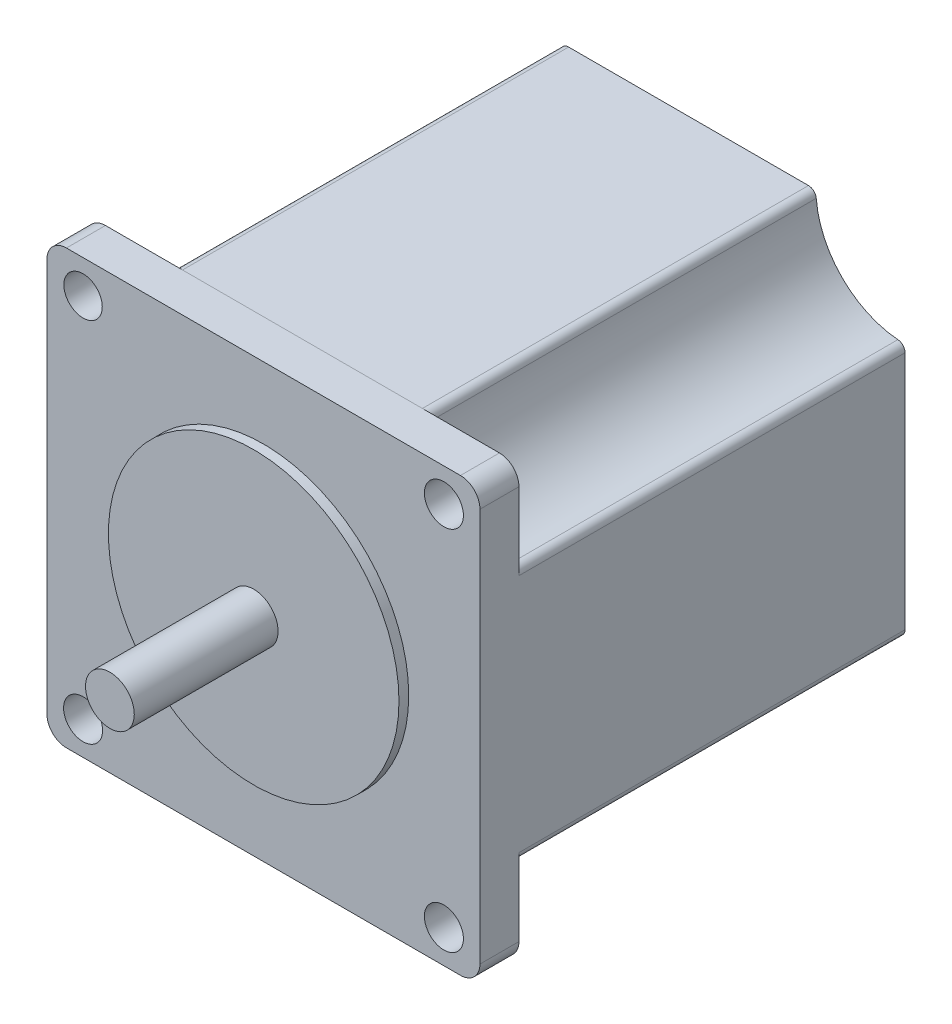
from build123d import *

# Parameters (mm, degrees)
BOSS_EXTRUDE1_DEPTH = 5.08
SKETCH2_R           = 2.5
SKETCH2_R_2         = 2.54
CUT_EXTRUDE1_DEPTH  = 12.7
SKETCH3_R           = 3.175
BOSS_EXTRUDE2_DEPTH = 20
BOSS_EXTRUDE3_DEPTH = 50.292
SKETCH7_R           = 5.08
CUT_EXTRUDE2_DEPTH  = 2.54
SKETCH8_W           = 4.445
SKETCH8_H           = 4.445
BOSS_EXTRUDE4_DEPTH = 2.54
SKETCH9_R           = 18.923
BOSS_EXTRUDE5_DEPTH = 1.27


with BuildPart() as part:
    # Sketch1 → Boss-Extrude1 (new body)
    with BuildSketch(Plane.XY):
        with BuildLine():
            Line((-25.66, 28.194), (25.66, 28.194))
            ThreePointArc((25.66, 28.194), (27.456051224, 27.450051224), (28.2, 25.654))
            Line((28.2, 25.654), (28.2, -25.654))
            ThreePointArc((28.2, -25.654), (27.456051224, -27.450051224), (25.66, -28.194))
            Line((25.66, -28.194), (-25.66, -28.194))
            ThreePointArc((-25.66, -28.194), (-27.456051224, -27.450051224), (-28.2, -25.654))
            Line((-28.2, -25.654), (-28.2, 25.654))
            ThreePointArc((-28.2, 25.654), (-27.456051224, 27.450051224), (-25.66, 28.194))
        make_face()
    extrude(amount=-BOSS_EXTRUDE1_DEPTH)

    # Sketch2 → Cut-Extrude1 (cut)
    with BuildSketch(Plane.XY):
        with Locations((-23.495, 23.876)):
            Circle(SKETCH2_R)
        with Locations((23.505, 23.876)):
            Circle(SKETCH2_R_2)
        with Locations((-23.495, -23.876)):
            Circle(SKETCH2_R_2)
        with Locations((23.505, -23.876)):
            Circle(SKETCH2_R_2)
    extrude(amount=-CUT_EXTRUDE1_DEPTH, mode=Mode.SUBTRACT)

    # Sketch3 → Boss-Extrude2 (add)
    with BuildSketch(Plane.XY):
        Circle(SKETCH3_R)
    extrude(amount=BOSS_EXTRUDE2_DEPTH)

    # Sketch6 → Boss-Extrude3 (add)
    with BuildSketch(Plane(origin=(0, 0, -5.08), x_dir=(-1, 0, 0), z_dir=(0, 0, -1))):
        with BuildLine():
            Line((-15.620607632, 28.193981005), (15.620607632, 28.193981005))
            ThreePointArc((15.620607632, 28.193981005), (16.309436696, 27.924821363), (16.633295319, 27.25995447))
            ThreePointArc((16.633295319, 27.25995447), (19.995115916, 19.990526597), (27.265660549, 16.631121879))
            ThreePointArc((27.265660549, 16.631121879), (27.930749509, 16.307360153), (28.200023614, 15.618407008))
            Line((28.200023614, 15.618407008), (28.200023614, -15.618407008))
            ThreePointArc((28.200023614, -15.618407008), (27.930742821, -16.307367402), (27.265640888, -16.631123464))
            ThreePointArc((27.265640888, -16.631123464), (19.994877492, -19.99046435), (16.632859418, -27.259990196))
            ThreePointArc((16.632859418, -27.259990196), (16.308995981, -27.924846048), (15.620173086, -28.194))
            Line((15.620173086, -28.194), (-15.620173086, -28.194))
            ThreePointArc((-15.620173086, -28.194), (-16.308986965, -27.924854363), (-16.632857438, -27.260014646))
            ThreePointArc((-16.632857438, -27.260014646), (-19.994954858, -19.990760744), (-27.265596467, -16.631665336))
            ThreePointArc((-27.265596467, -16.631665336), (-27.93071213, -16.307915269), (-28.2, -15.618947204))
            Line((-28.2, -15.618947204), (-28.2, 15.618947204))
            ThreePointArc((-28.2, 15.618947204), (-27.930718818, 16.30790802), (-27.265616128, 16.631663752))
            ThreePointArc((-27.265616128, 16.631663752), (-19.995193282, 19.990822991), (-16.633293339, 27.25997892))
            ThreePointArc((-16.633293339, 27.25997892), (-16.30942768, 27.924829678), (-15.620607632, 28.193981005))
        make_face()
    extrude(amount=BOSS_EXTRUDE3_DEPTH)

    # Sketch7 → Cut-Extrude2 (cut)
    with BuildSketch(Plane(origin=(0, 0, -55.372), x_dir=(-1, 0, 0), z_dir=(0, 0, -1))):
        Circle(SKETCH7_R)
    extrude(amount=-CUT_EXTRUDE2_DEPTH, mode=Mode.SUBTRACT)

    # Sketch8 → Boss-Extrude4 (add)
    with BuildSketch(Plane(origin=(0, -28.194, 0), x_dir=(-1, 0, 0), z_dir=(0, -1, 0))):
        with Locations((0, 49.3395)):
            Rectangle(SKETCH8_W, SKETCH8_H)
    extrude(amount=BOSS_EXTRUDE4_DEPTH)

    # Sketch9 → Boss-Extrude5 (add)
    with BuildSketch(Plane.XY):
        Circle(SKETCH9_R)
    extrude(amount=BOSS_EXTRUDE5_DEPTH)


solid = part.part
